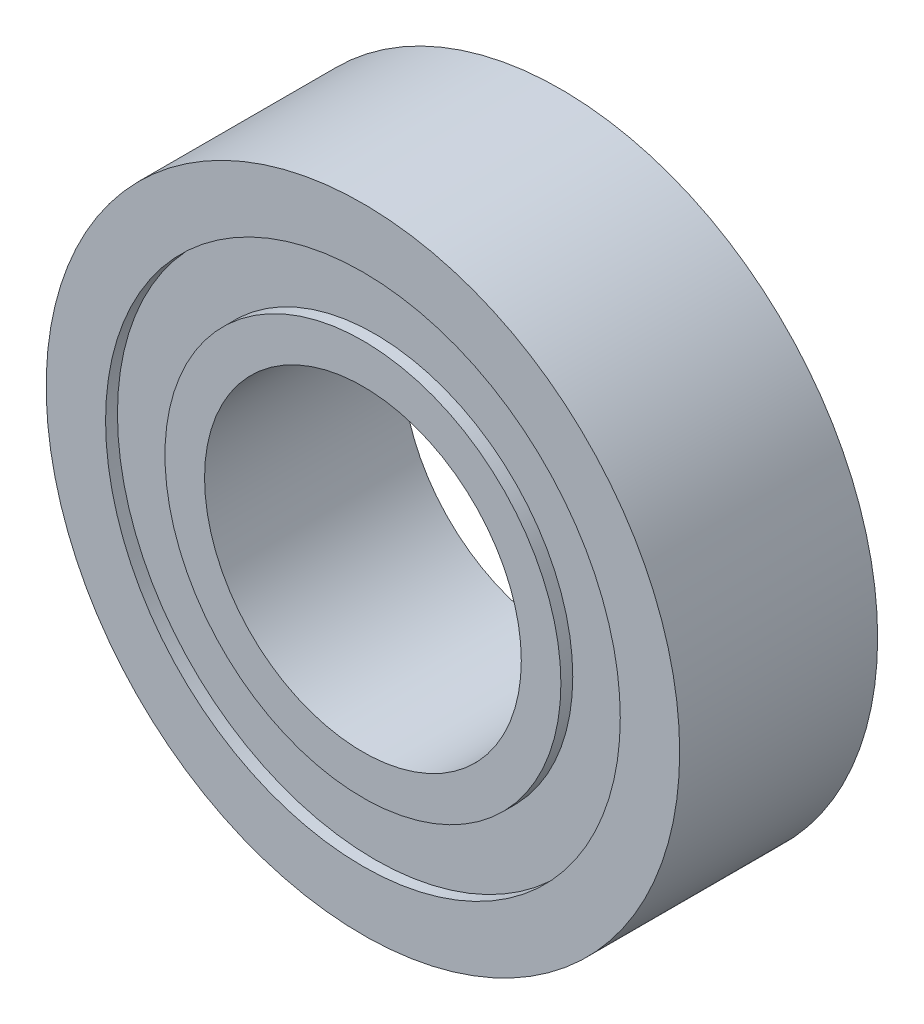
from build123d import *

# Parameters (mm, degrees)
BODY_DEPTH       = 2.5
BODY_DEPTH_BACK  = 2.5
SKETCH1_R        = 8
SKETCH3_R        = 4
BORE_HOLE_DEPTH  = 13.369316877
SKETCH4_R        = 6.5
SKETCH4_R_2      = 5
DECORATION_DEPTH = 0.3


with BuildPart() as part:
    # Sketch1 → Body (new, two sides: drawn at the far end of the back side and taken through both)
    with BuildSketch(Plane.XY.offset(-BODY_DEPTH_BACK)):
        Circle(SKETCH1_R)
    extrude(amount=BODY_DEPTH + BODY_DEPTH_BACK)

    # Sketch3 → Bore-Hole (cut, through all)
    with BuildSketch(Plane.XY.offset(2.5)):
        Circle(SKETCH3_R)
    extrude(amount=-BORE_HOLE_DEPTH, mode=Mode.SUBTRACT)

    # Sketch4 → Decoration (cut)
    with BuildSketch(Plane.XY.offset(2.5)):
        Circle(SKETCH4_R)
        Circle(SKETCH4_R_2, mode=Mode.SUBTRACT)
    decoration = extrude(amount=-DECORATION_DEPTH, mode=Mode.SUBTRACT)

    # Mirror1: Decoration across plane
    add(decoration.mirror(Plane.XY), mode=Mode.SUBTRACT)


solid = part.part
